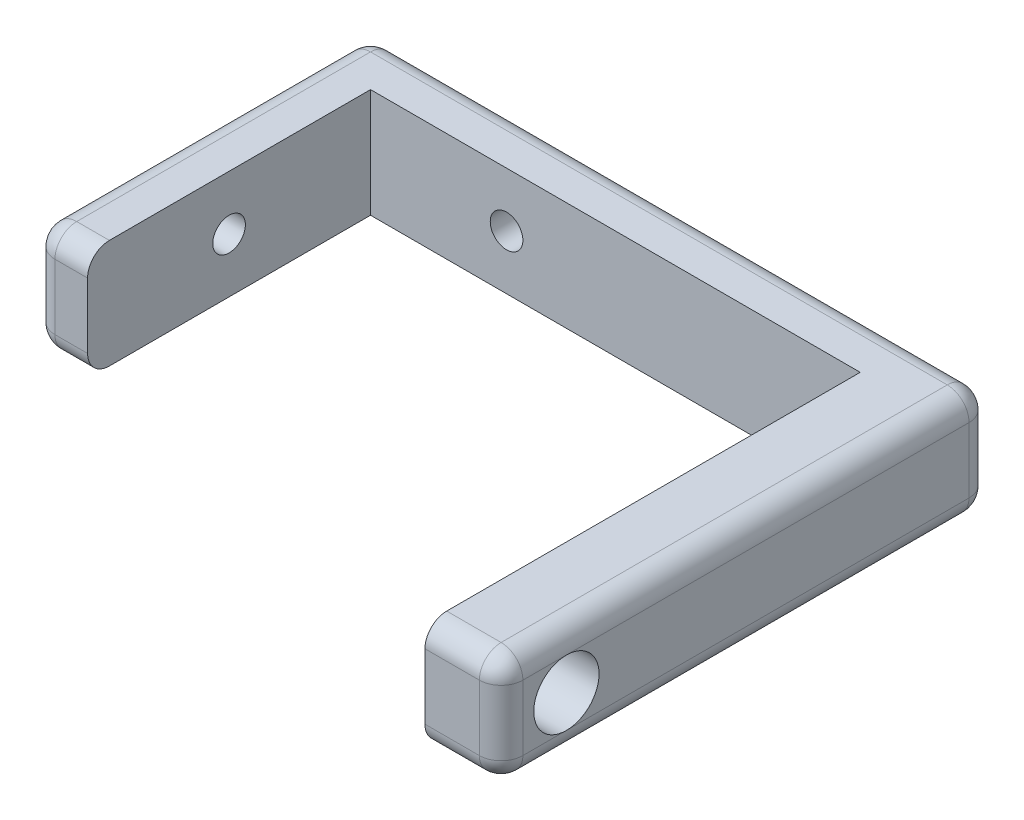
from build123d import *

# Parameters (mm, degrees)
BOSS_EXTRUDE1_DEPTH = 10
SKETCH3_R           = 2.9999999999999973
CUT_EXTRUDE1_DEPTH  = 10
FILLET3_R           = 2
SKETCH4_R           = 1.4999999999999998
CUT_EXTRUDE2_DEPTH  = 10
SKETCH5_R           = 1.5000000000000002
CUT_EXTRUDE3_DEPTH  = 10


with BuildPart() as part:
    # Sketch2 → Boss-Extrude1 (new body)
    with BuildSketch(Plane(origin=(0, 0, 0), x_dir=(1, 0, 0), z_dir=(0, 1, 0))):
        Polygon((32.000000000000014, -27.000000000000004), (39.000000000000014, -27.000000000000004), (39.00000000000001, 18.000000000000004), (-18, 18), (-18, -13), (-12.999999999999998, -13), (-12.999999999999998, 13), (13.000000000000002, 13), (32, 13), align=None)
    extrude(amount=BOSS_EXTRUDE1_DEPTH)

    # Sketch3 → Cut-Extrude1 (cut)
    with BuildSketch(Plane(origin=(39.00000000000001, 0, -6.01e-15), x_dir=(0, 0, -1), z_dir=(1, 0, 0))):
        with Locations((-21, 5)):
            Circle(SKETCH3_R)
    extrude(amount=-CUT_EXTRUDE1_DEPTH, mode=Mode.SUBTRACT)

    # Fillet3
    fillet3_edges = [part.edges().sort_by_distance(p)[0] for p in [
        (-15.5, 0, 13),
        (-18, 0, -2.5),
        (10.500000000000004, 0, -18),
        (39.000000000000014, 0, 4.5),
        (35.500000000000014, 0, 27.000000000000004),
        (10.500000000000004, 10, -18),
        (-18, 5, 13),
        (-18, 5, -18),
        (39.00000000000001, 5, -18.000000000000004),
        (39.000000000000014, 5, 27.000000000000004),
        (-18, 10, -2.5),
        (-15.5, 10, 13),
        (35.500000000000014, 10, 27.000000000000004),
        (39.000000000000014, 10, 4.5),
    ]]
    fillet(fillet3_edges, radius=FILLET3_R)

    # Sketch4 → Cut-Extrude2 (cut)
    with BuildSketch(Plane(origin=(-1.1e-15, 0, -18), x_dir=(-1, 0, 6e-17), z_dir=(-6e-17, 0, -1))):
        with Locations((0.5000000000000004, 5)):
            Circle(SKETCH4_R)
    extrude(amount=-CUT_EXTRUDE2_DEPTH, mode=Mode.SUBTRACT)

    # Sketch5 → Cut-Extrude3 (cut)
    with BuildSketch(Plane.ZY.offset(18)):
        with Locations((3.47e-15, 5)):
            Circle(SKETCH5_R)
    extrude(amount=-CUT_EXTRUDE3_DEPTH, mode=Mode.SUBTRACT)


solid = part.part
